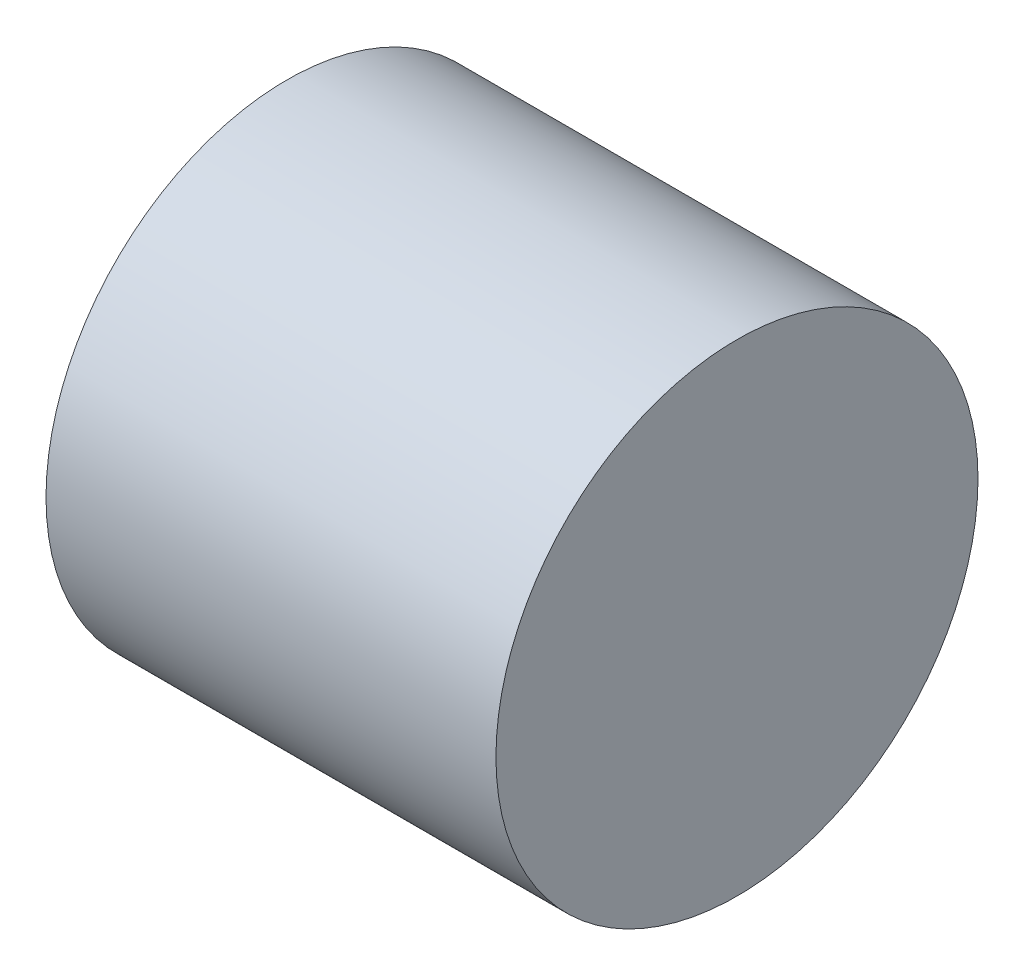
from build123d import *


with BuildPart() as part:
    # Sketch2 → Revolve1 (revolve)
    with BuildSketch(Plane.XY):
        Polygon((0, 4), (0, 7.5), (14, 7.5), (14, 0), (12.309401077, 0), (10, 4), align=None)
    revolve(axis=Axis((0, 0, 0), (1, 0, 0)))


solid = part.part
